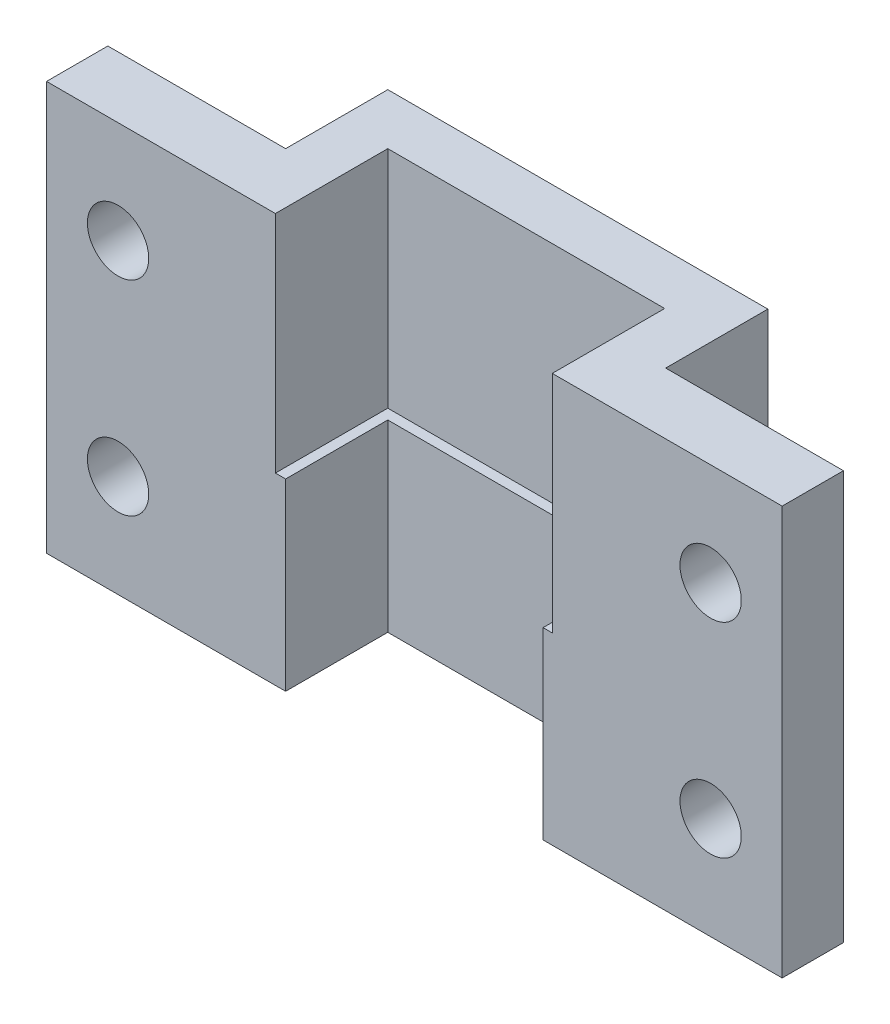
from build123d import *

# Parameters (mm, degrees)
BOSS_EXTRUDE1_DEPTH = 20
SKETCH2_R           = 1.5
CUT_EXTRUDE1_DEPTH  = 16
CUT_EXTRUDE2_DEPTH  = 11


with BuildPart() as part:
    # Sketch1 → Boss-Extrude1 (new body)
    with BuildSketch(Plane(origin=(0, 0, 0), x_dir=(1, 0, 0), z_dir=(0, 1, 0))):
        Polygon((16.770422535, -3), (28.470422535, -3), (28.470422535, 0), (19.770422535, 0), (19.770422535, 5), (1.170422535, 5), (1.170422535, 0), (-7.529577465, 0), (-7.529577465, -3), (4.170422535, -3), (4.170422535, 2), (16.770422535, 2), align=None)
    extrude(amount=BOSS_EXTRUDE1_DEPTH)

    # Sketch2 → Cut-Extrude1 (cut)
    with BuildSketch(Plane(origin=(0, 0, 0), x_dir=(-1, 0, 0), z_dir=(0, 0, -1))):
        with Locations((4.029577465, 15)):
            Circle(SKETCH2_R)
        with Locations((4.029577465, 5)):
            Circle(SKETCH2_R)
        with Locations((-24.970422535, 5)):
            Circle(SKETCH2_R)
        with Locations((-24.970422535, 15)):
            Circle(SKETCH2_R)
    extrude(amount=-CUT_EXTRUDE1_DEPTH, mode=Mode.SUBTRACT)

    # Sketch3 → Cut-Extrude2 (cut)
    with BuildSketch(Plane(origin=(0, 20, 0), x_dir=(1, 0, 0), z_dir=(0, 1, 0))):
        Polygon((4.170422535, -3), (4.170422535, 2), (16.770422535, 2), (16.770422535, -3), (17.220422535, -3), (17.220422535, 2.5), (3.670422535, 2.5), (3.670422535, -3), align=None)
    extrude(amount=-CUT_EXTRUDE2_DEPTH, mode=Mode.SUBTRACT)


solid = part.part
